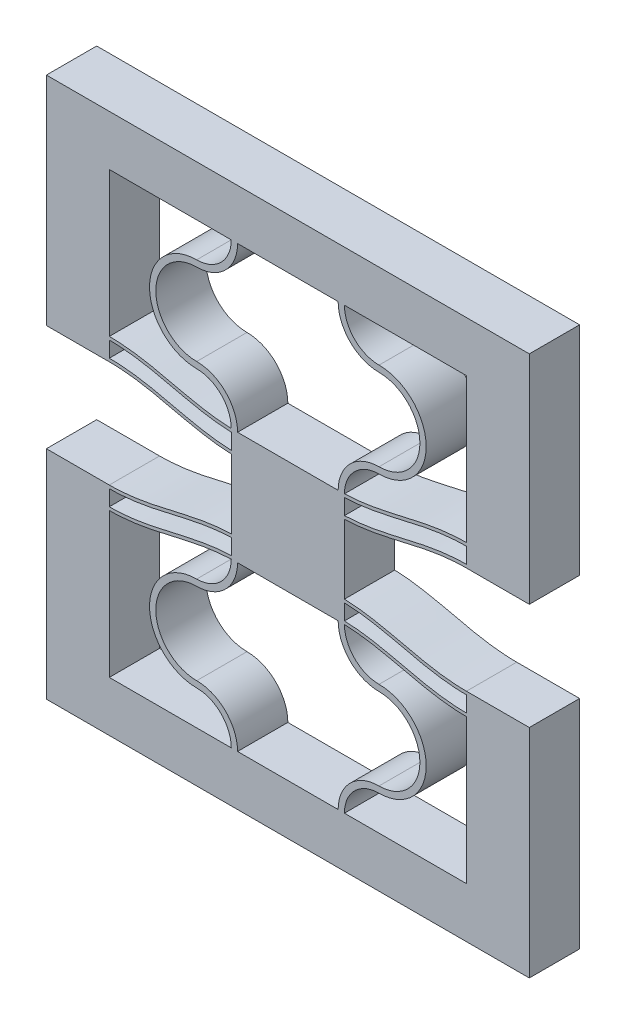
from build123d import *

# Parameters (mm, degrees)
BOSS_EXTRUDE1_DEPTH = 4
SKETCH4_W           = 1.000028655
SKETCH4_H           = 4
BOSS_EXTRUDE2_DEPTH = 1.5
SKETCH7_W           = 4
SKETCH7_H           = 4
SKETCH7_H_2         = 8.982246023
BOSS_EXTRUDE3_DEPTH = 4


with BuildPart() as part:
    # Sketch1 → Boss-Extrude1 (new body)
    with BuildSketch(Plane.XY):
        with BuildLine():
            add(Edge.make_bspline(
                [(10.700014224, 14.741123012), (10.769414318, 14.738663695), (11.03310814, 14.727603281), (11.490614063, 14.697170592), (12.262749669, 14.614202549), (13.344934017, 14.437909286), (14.416347819, 14.207015891), (15.483183095, 13.956131655), (16.319838847, 13.766249034), (16.857815383, 13.652304096), (17.362886901, 13.553302991), (17.776414428, 13.479790745), (18.203500731, 13.412396588), (18.656257538, 13.353987061), (18.987768381, 13.3179099), (19.289919617, 13.293036934), (19.513652899, 13.276508776), (19.742348402, 13.265861771), (19.917436469, 13.255829602), (20.20131205, 13.251344917), (20.318835942, 13.249999512), (20.4, 13.249999512)],
                knots=[0.520196639, 0.520196639, 0.520196639, 0.520196639, 0.520196639, 0.53141408, 0.562828159, 0.594242235, 0.645597029, 0.708425214, 0.739839305, 0.771253396, 0.784217346, 0.797181296, 0.823109196, 0.838816246, 0.854523296, 0.870230336, 0.878083855, 0.885937375, 0.893790894, 0.901644413, 0.917351451, 0.917351451, 0.917351451, 0.917351451, 0.917351451], degree=4))
            Line((10.700014224, 14.741123012), (10.700014224, 15.991123012))
            Line((10.700014224, 15.991123012), (9.699985569, 15.991123012))
            Line((9.699985569, 15.991123012), (9.699985569, 14.741123012))
            add(Edge.make_bspline(
                [(0, 13.249999512), (0.081164058, 13.249999512), (0.199729304, 13.251344907), (0.473779629, 13.255829663), (0.709191365, 13.267868104), (1.033438356, 13.285149543), (1.35158977, 13.312755641), (1.750162777, 13.353987577), (2.192328474, 13.412395709), (2.7057608, 13.49221948), (3.305792882, 13.602949191), (4.002230953, 13.748490017), (4.916593693, 13.956132269), (5.983810028, 14.207015465), (7.054976456, 14.437909533), (8.137289789, 14.614202431), (8.909375138, 14.697170645), (9.366886361, 14.727603295), (9.630584373, 14.738663696), (9.699985569, 14.741123012)],
                knots=[0.082648549, 0.082648549, 0.082648549, 0.082648549, 0.082648549, 0.098355587, 0.106209106, 0.114062625, 0.129769664, 0.145476704, 0.161183754, 0.176890804, 0.202818704, 0.228746604, 0.260160695, 0.291574786, 0.354402971, 0.405757765, 0.437171841, 0.46858592, 0.479803371, 0.479803371, 0.479803371, 0.479803371, 0.479803371], degree=4))
            Line((0, 13.249999512), (-5.000000005, 13.249999512))
            Line((-5.000000005, 13.249999512), (-5.000000005, -4))
            Line((-5.000000005, -4), (25.400000005, -4))
            Line((25.400000005, -4), (25.400000005, 13.249999512))
            Line((25.400000005, 13.249999512), (20.4, 13.249999512))
        make_face()
        with BuildLine():
            Line((9.699985569, 14.491123012), (9.699985569, 13.241123012))
            add(Edge.make_bspline(
                [(0, 11.749999512), (0.081164058, 11.749999512), (0.199729304, 11.751344907), (0.473779629, 11.755829663), (0.709191365, 11.767868104), (1.033438356, 11.785149543), (1.35158977, 11.812755641), (1.750162777, 11.853987577), (2.192328474, 11.912395709), (2.7057608, 11.99221948), (3.305792882, 12.102949191), (4.002230953, 12.248490017), (4.916593693, 12.456132269), (5.983810028, 12.707015465), (7.054976456, 12.937909533), (8.137289789, 13.114202431), (8.909375138, 13.197170645), (9.366886361, 13.227603295), (9.630584373, 13.238663696), (9.699985569, 13.241123012)],
                knots=[0.082648549, 0.082648549, 0.082648549, 0.082648549, 0.082648549, 0.098355587, 0.106209106, 0.114062625, 0.129769664, 0.145476704, 0.161183754, 0.176890804, 0.202818704, 0.228746604, 0.260160695, 0.291574786, 0.354402971, 0.405757765, 0.437171841, 0.46858592, 0.479803371, 0.479803371, 0.479803371, 0.479803371, 0.479803371], degree=4))
            Line((0, 11.749999512), (0, 12.999999512))
            add(Edge.make_bspline(
                [(0, 12.999999512), (0.081164058, 12.999999512), (0.199729304, 13.001344907), (0.473779629, 13.005829663), (0.709191365, 13.017868104), (1.033438356, 13.035149543), (1.35158977, 13.062755641), (1.750162777, 13.103987577), (2.192328474, 13.162395709), (2.7057608, 13.24221948), (3.305792882, 13.352949191), (4.002230953, 13.498490017), (4.916593693, 13.706132269), (5.983810028, 13.957015465), (7.054976456, 14.187909533), (8.137289789, 14.364202431), (8.909375138, 14.447170645), (9.366886361, 14.477603295), (9.630584373, 14.488663696), (9.699985569, 14.491123012)],
                knots=[0.082648549, 0.082648549, 0.082648549, 0.082648549, 0.082648549, 0.098355587, 0.106209106, 0.114062625, 0.129769664, 0.145476704, 0.161183754, 0.176890804, 0.202818704, 0.228746604, 0.260160695, 0.291574786, 0.354402971, 0.405757765, 0.437171841, 0.46858592, 0.479803371, 0.479803371, 0.479803371, 0.479803371, 0.479803371], degree=4))
        make_face(mode=Mode.SUBTRACT)
        with BuildLine():
            Line((10.700014224, 13.241123012), (10.700014224, 14.491123012))
            add(Edge.make_bspline(
                [(10.700014224, 14.491123012), (10.769414318, 14.488663695), (11.03310814, 14.477603281), (11.490614063, 14.447170592), (12.262749669, 14.364202549), (13.344934017, 14.187909286), (14.416347819, 13.957015891), (15.483183095, 13.706131655), (16.319838847, 13.516249034), (16.857815383, 13.402304096), (17.362886901, 13.303302991), (17.776414428, 13.229790745), (18.203500731, 13.162396588), (18.656257538, 13.103987061), (18.987768381, 13.0679099), (19.289919617, 13.043036934), (19.513652899, 13.026508776), (19.742348402, 13.015861771), (19.917436469, 13.005829602), (20.20131205, 13.001344917), (20.318835942, 12.999999512), (20.4, 12.999999512)],
                knots=[0.520196639, 0.520196639, 0.520196639, 0.520196639, 0.520196639, 0.53141408, 0.562828159, 0.594242235, 0.645597029, 0.708425214, 0.739839305, 0.771253396, 0.784217346, 0.797181296, 0.823109196, 0.838816246, 0.854523296, 0.870230336, 0.878083855, 0.885937375, 0.893790894, 0.901644413, 0.917351451, 0.917351451, 0.917351451, 0.917351451, 0.917351451], degree=4))
            Line((20.4, 12.999999512), (20.4, 11.749999512))
            add(Edge.make_bspline(
                [(10.700014224, 13.241123012), (10.769414318, 13.238663695), (11.03310814, 13.227603281), (11.490614063, 13.197170592), (12.262749669, 13.114202549), (13.344934017, 12.937909286), (14.416347819, 12.707015891), (15.483183095, 12.456131655), (16.319838847, 12.266249034), (16.857815383, 12.152304096), (17.362886901, 12.053302991), (17.776414428, 11.979790745), (18.203500731, 11.912396588), (18.656257538, 11.853987061), (18.987768381, 11.8179099), (19.289919617, 11.793036934), (19.513652899, 11.776508776), (19.742348402, 11.765861771), (19.917436469, 11.755829602), (20.20131205, 11.751344917), (20.318835942, 11.749999512), (20.4, 11.749999512)],
                knots=[0.520196639, 0.520196639, 0.520196639, 0.520196639, 0.520196639, 0.53141408, 0.562828159, 0.594242235, 0.645597029, 0.708425214, 0.739839305, 0.771253396, 0.784217346, 0.797181296, 0.823109196, 0.838816246, 0.854523296, 0.870230336, 0.878083855, 0.885937375, 0.893790894, 0.901644413, 0.917351451, 0.917351451, 0.917351451, 0.917351451, 0.917351451], degree=4))
        make_face(mode=Mode.SUBTRACT)
        with BuildLine():
            Line((0, 0), (0, 11.499999512))
            add(Edge.make_bspline(
                [(0, 11.499999512), (0.081164058, 11.499999512), (0.199729304, 11.501344907), (0.473779629, 11.505829663), (0.709191365, 11.517868104), (1.033438356, 11.535149543), (1.35158977, 11.562755641), (1.750162777, 11.603987577), (2.192328474, 11.662395709), (2.7057608, 11.74221948), (3.305792882, 11.852949191), (4.002230953, 11.998490017), (4.916593693, 12.206132269), (5.983810028, 12.457015465), (7.054976456, 12.687909533), (8.137289789, 12.864202431), (8.909375138, 12.947170645), (9.366886361, 12.977603295), (9.630584373, 12.988663696), (9.699985569, 12.991123012)],
                knots=[0.082648549, 0.082648549, 0.082648549, 0.082648549, 0.082648549, 0.098355587, 0.106209106, 0.114062625, 0.129769664, 0.145476704, 0.161183754, 0.176890804, 0.202818704, 0.228746604, 0.260160695, 0.291574786, 0.354402971, 0.405757765, 0.437171841, 0.46858592, 0.479803371, 0.479803371, 0.479803371, 0.479803371, 0.479803371], degree=4))
            ThreePointArc((9.699985569, 12.991123012), (8.891402518, 11.052320391), (6.949999896, 10.25))
            ThreePointArc((6.949999896, 10.25), (3.199999896, 6.5), (6.949999896, 2.75))
            ThreePointArc((6.949999896, 2.75), (8.894543545, 1.944543648), (9.699999896, 0))
            Line((9.699999896, 0), (0, 0))
        make_face(mode=Mode.SUBTRACT)
        with BuildLine():
            ThreePointArc((6.949999896, 9.75), (9.248096935, 10.701902961), (10.199999896, 13))
            ThreePointArc((10.199999896, 13), (11.151902857, 10.701902961), (13.449999896, 9.75))
            ThreePointArc((13.449999896, 9.75), (16.699999896, 6.5), (13.449999896, 3.25))
            ThreePointArc((13.449999896, 3.25), (11.151902857, 2.298097039), (10.199999896, 0))
            ThreePointArc((10.199999896, 0), (9.248096935, 2.298097039), (6.949999896, 3.25))
            ThreePointArc((6.949999896, 3.25), (3.699999896, 6.5), (6.949999896, 9.75))
        make_face(mode=Mode.SUBTRACT)
        with BuildLine():
            ThreePointArc((13.449999896, 10.25), (11.508597274, 11.052320391), (10.700014224, 12.991123012))
            add(Edge.make_bspline(
                [(10.700014224, 12.991123012), (10.769414318, 12.988663695), (11.03310814, 12.977603281), (11.490614063, 12.947170592), (12.262749669, 12.864202549), (13.344934017, 12.687909286), (14.416347819, 12.457015891), (15.483183095, 12.206131655), (16.319838847, 12.016249034), (16.857815383, 11.902304096), (17.362886901, 11.803302991), (17.776414428, 11.729790745), (18.203500731, 11.662396588), (18.656257538, 11.603987061), (18.987768381, 11.5679099), (19.289919617, 11.543036934), (19.513652899, 11.526508776), (19.742348402, 11.515861771), (19.917436469, 11.505829602), (20.20131205, 11.501344917), (20.318835942, 11.499999512), (20.4, 11.499999512)],
                knots=[0.520196639, 0.520196639, 0.520196639, 0.520196639, 0.520196639, 0.53141408, 0.562828159, 0.594242235, 0.645597029, 0.708425214, 0.739839305, 0.771253396, 0.784217346, 0.797181296, 0.823109196, 0.838816246, 0.854523296, 0.870230336, 0.878083855, 0.885937375, 0.893790894, 0.901644413, 0.917351451, 0.917351451, 0.917351451, 0.917351451, 0.917351451], degree=4))
            Line((20.4, 11.499999512), (20.4, 0))
            Line((20.4, 0), (10.699999896, 0))
            ThreePointArc((10.699999896, 0), (11.505456248, 1.944543648), (13.449999896, 2.75))
            ThreePointArc((13.449999896, 2.75), (17.199999896, 6.5), (13.449999896, 10.25))
        make_face(mode=Mode.SUBTRACT)
    extrude(amount=BOSS_EXTRUDE1_DEPTH)

    # Sketch4 → Boss-Extrude2 (add)
    with BuildSketch(Plane(origin=(0, 15.991123012, 0), x_dir=(1, 0, 0), z_dir=(0, 1, 0))):
        with Locations((10.199999896, -2)):
            Rectangle(SKETCH4_W, SKETCH4_H)
    extrude(amount=BOSS_EXTRUDE2_DEPTH)

    # Mirror3: part across plane


with BuildPart() as part_1:
    add(part.part)
    add(part.part.mirror(Plane.ZX.offset(17.491123012)))

    # Split2
    split(bisect_by=Plane(origin=(10.199999896, 0, 0), x_dir=(0, -1, 0), z_dir=(-1, 0, 0)), keep=Keep.BOTTOM)

    # Sketch7 → Boss-Extrude3 (add)
    with BuildSketch(Plane.ZY.offset(-10.199999896)):
        with Locations((2, 36.982246023)):
            Rectangle(SKETCH7_W, SKETCH7_H)
        with Locations((2, 17.491123012)):
            Rectangle(SKETCH7_W, SKETCH7_H_2)
        with Locations((2, -2)):
            Rectangle(SKETCH7_W, SKETCH7_H)
    extrude(amount=BOSS_EXTRUDE3_DEPTH)

    # Mirror2: part across plane


with BuildPart() as part_2:
    add(part_1.part)
    add(part_1.part.mirror(Plane.ZY.offset(-6.199999896)))


solid = part_2.part
